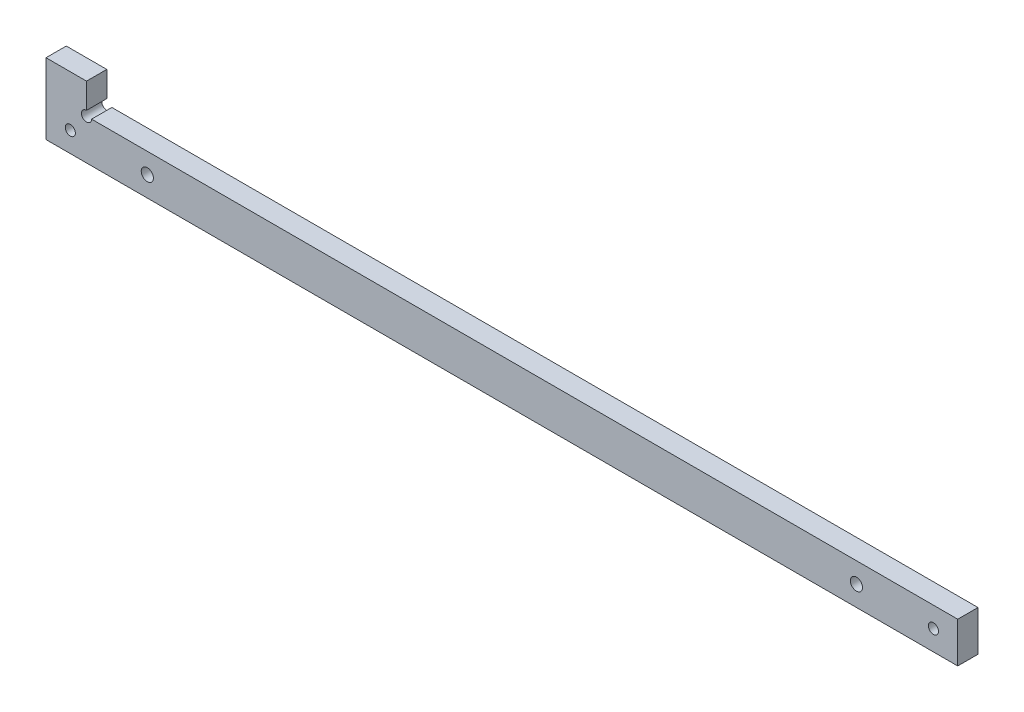
from build123d import *

# Parameters (mm, degrees)
BOSS_EXTRUDE1_DEPTH = 10
SKETCH3_R           = 3
SKETCH3_R_2         = 2.5
CUT_EXTRUDE2_DEPTH  = 11


with BuildPart() as part:
    # Sketch1 → Boss-Extrude1 (new body)
    with BuildSketch(Plane.XY):
        with BuildLine():
            Line((0, 15), (0, 2.5))
            ThreePointArc((0, 2.5), (-1.767766953, -1.767766953), (2.5, 0))
            Line((2.5, 0), (430, 0))
            Line((430, 0), (430, -20))
            Line((430, -20), (-20, -20))
            Line((-20, -20), (-20, 15))
            Line((-20, 15), (0, 15))
        make_face()
    extrude(amount=BOSS_EXTRUDE1_DEPTH)

    # Sketch3 → Cut-Extrude2 (cut, through all)
    with BuildSketch(Plane.XY.offset(10)):
        with Locations((30, -10)):
            Circle(SKETCH3_R)
        with Locations((380, -10)):
            Circle(SKETCH3_R)
        with Locations((-8, -10)):
            Circle(SKETCH3_R_2)
        with Locations((418, -10)):
            Circle(SKETCH3_R_2)
    extrude(amount=-CUT_EXTRUDE2_DEPTH, mode=Mode.SUBTRACT)


solid = part.part
